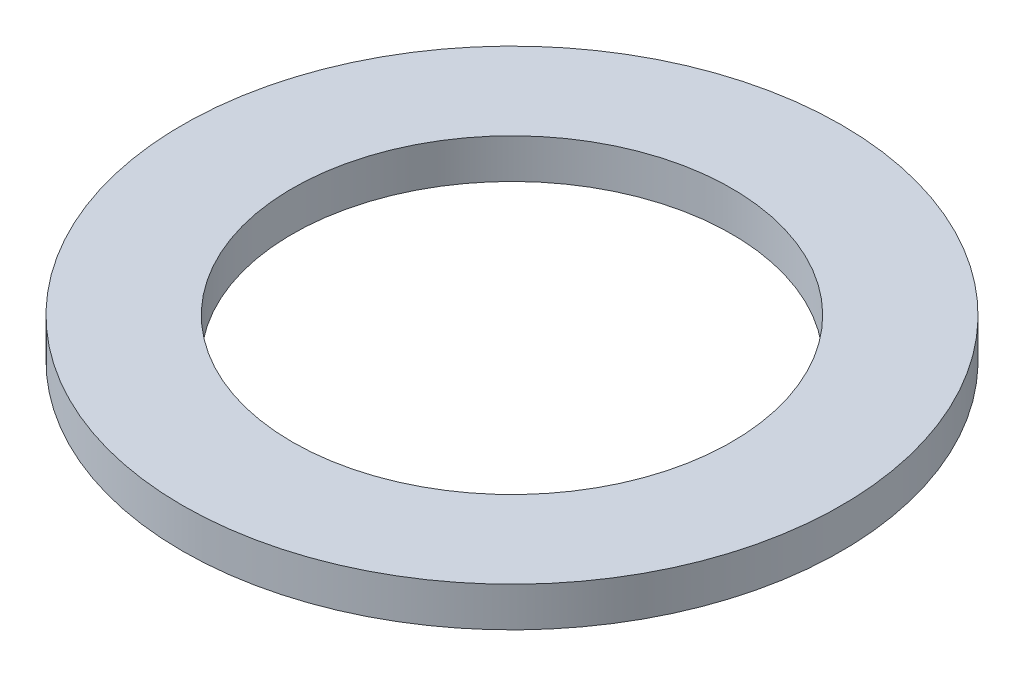
from build123d import *

# Parameters (mm, degrees)
IZIM1_R                     = 7.5
IZIM1_R_2                   = 5
Y_KSEKLIK_EKSTR_ZYON1_DEPTH = 0.9


with BuildPart() as part:
    # Çizim1 → Yükseklik-Ekstrüzyon1 (new body)
    with BuildSketch(Plane(origin=(0, 0, 0), x_dir=(1, 0, 0), z_dir=(0, 1, 0))):
        Circle(IZIM1_R)
        Circle(IZIM1_R_2, mode=Mode.SUBTRACT)
    extrude(amount=Y_KSEKLIK_EKSTR_ZYON1_DEPTH)


solid = part.part
